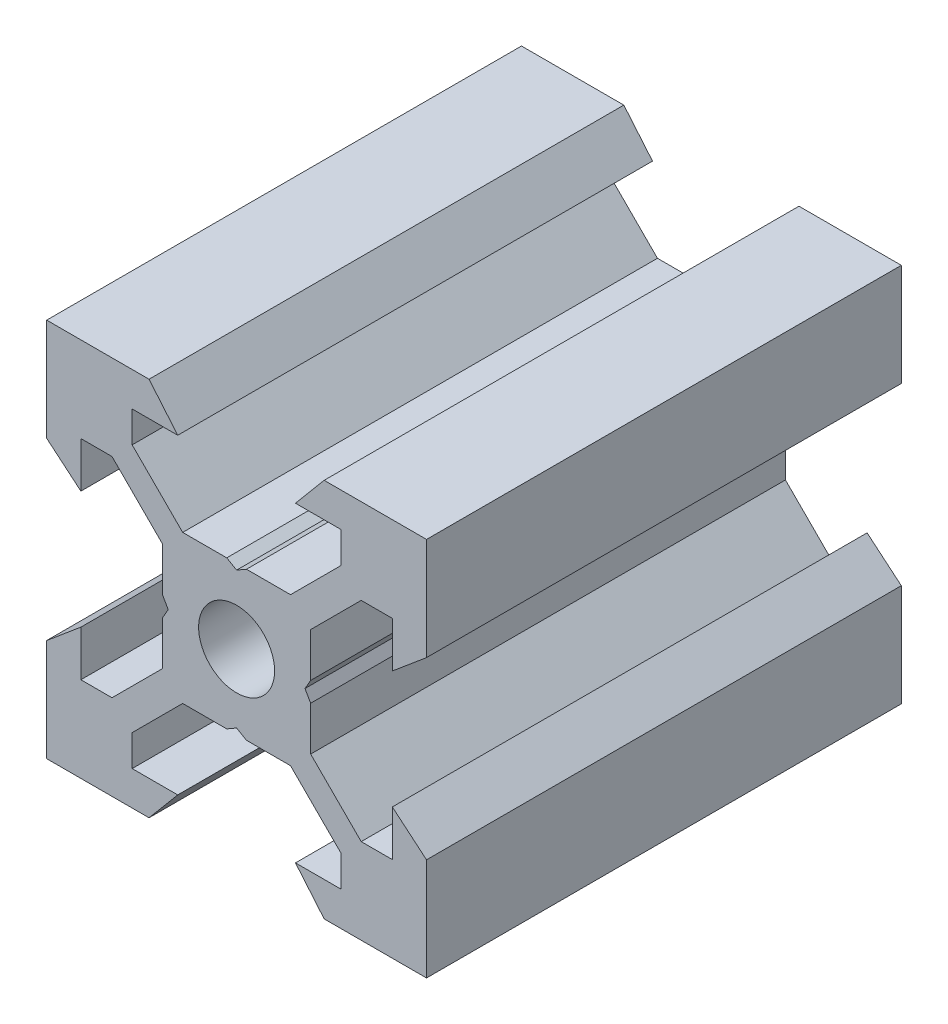
from build123d import *

# Parameters (mm, degrees)
SKETCH1_R           = 2
BOSS_EXTRUDE1_DEPTH = 12.5


with BuildPart() as part:
    # Sketch1 → Boss-Extrude1 (new body, symmetric)
    with BuildSketch(Plane.XY):
        Polygon((10, 10), (10, 4.610379336), (8.2, 3.1), (8.2, 5.5), (6.560660172, 5.5), (3.9, 2.839339828), (3.9, 0.519615242), (3.6, 0), (3.9, -0.519615242), (3.9, -2.839339828), (6.560660172, -5.5), (8.2, -5.5), (8.2, -3.1), (10, -4.610379336), (10, -10), (4.610379336, -10), (3.1, -8.2), (5.5, -8.2), (5.5, -6.560660172), (2.839339828, -3.9), (0.519615242, -3.9), (0, -3.6), (-0.519615242, -3.9), (-2.839339828, -3.9), (-5.5, -6.560660172), (-5.5, -8.2), (-3.1, -8.2), (-4.610379336, -10), (-10, -10), (-10, -4.610379336), (-8.2, -3.1), (-8.2, -5.5), (-6.560660172, -5.5), (-3.9, -2.839339828), (-3.9, -0.519615242), (-3.6, 0), (-3.9, 0.519615242), (-3.9, 2.839339828), (-6.560660172, 5.5), (-8.2, 5.5), (-8.2, 3.1), (-10, 4.610379336), (-10, 10), (-4.610379336, 10), (-3.1, 8.2), (-5.5, 8.2), (-5.5, 6.560660172), (-2.839339828, 3.9), (-0.519615242, 3.9), (0, 3.6), (0.519615242, 3.9), (2.839339828, 3.9), (5.5, 6.560660172), (5.5, 8.2), (3.1, 8.2), (4.610379336, 10), align=None)
        Circle(SKETCH1_R, mode=Mode.SUBTRACT)
    extrude(amount=BOSS_EXTRUDE1_DEPTH, both=True)


solid = part.part
